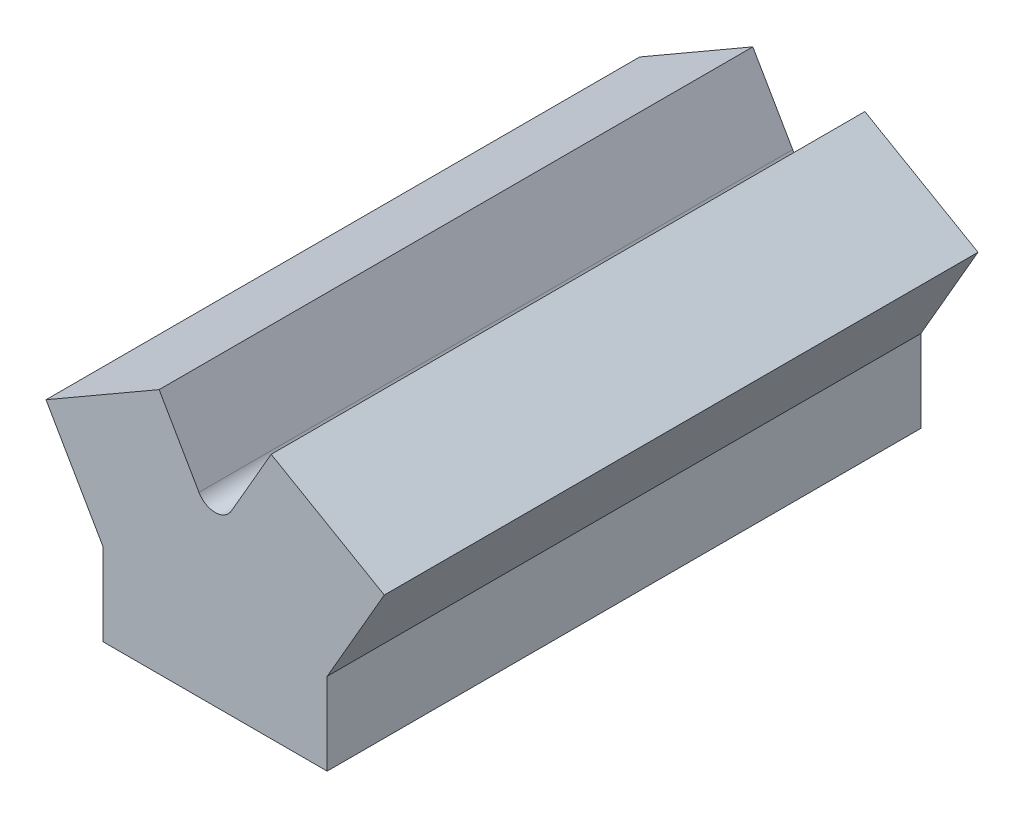
from build123d import *

# Parameters (mm, degrees)
BOSS_EXTRUDE1_DEPTH = 403.86
CUT_EXTRUDE1_START  = -19.05
SKETCH3_R           = 22.86
CUT_EXTRUDE1_DEPTH  = 403.86
CUT_EXTRUDE2_START  = -19.05
SKETCH2_R           = 22.86
CUT_EXTRUDE2_DEPTH  = 403.86
CUT_EXTRUDE3_START  = -25.4
CUT_EXTRUDE3_DEPTH  = 353.06
SKETCH7_R           = 6.35
CUT_EXTRUDE4_DEPTH  = 76.2


with BuildPart() as part:
    # Sketch1 → Boss-Extrude1 (new body)
    with BuildSketch(Plane.XY):
        with BuildLine():
            ThreePointArc((10.998522628, 120.65), (0, 114.3), (-10.998522628, 120.65))
            Line((-10.998522628, 120.65), (-38.114105889, 167.615567884))
            Line((-38.114105889, 167.615567884), (-115.061446619, 123.19))
            Line((-115.061446619, 123.19), (-76.2, 55.88))
            Line((-76.2, 55.88), (-76.2, 0))
            Line((-76.2, 0), (76.2, 0))
            Line((76.2, 0), (76.2, 55.88))
            Line((76.2, 55.88), (115.061446619, 123.19))
            Line((115.061446619, 123.19), (38.114105889, 167.615567884))
            Line((38.114105889, 167.615567884), (10.998522628, 120.65))
        make_face()
    extrude(amount=BOSS_EXTRUDE1_DEPTH)

    # Sketch3 → Cut-Extrude1 (cut)
    with BuildSketch(Plane(origin=(-82.108196401, 142.215567884, 0), x_dir=(0.866025404, 0.5, 0), z_dir=(-0.5, 0.866025404, 0)).offset(CUT_EXTRUDE1_START)):
        with Locations((6.374432116, -340.36)):
            Circle(SKETCH3_R)
        with Locations((6.374432116, -228.6)):
            Circle(SKETCH3_R)
        with Locations((6.374432116, -116.84)):
            Circle(SKETCH3_R)
    extrude(amount=-CUT_EXTRUDE1_DEPTH, mode=Mode.SUBTRACT)

    # Sketch2 → Cut-Extrude2 (cut)
    with BuildSketch(Plane(origin=(82.108196401, 142.215567884, 0), x_dir=(0.866025404, -0.5, 0), z_dir=(0.5, 0.866025404, 0)).offset(CUT_EXTRUDE2_START)):
        with Locations((-6.374432116, -284.48)):
            Circle(SKETCH2_R)
        with Locations((-6.374432116, -172.72)):
            Circle(SKETCH2_R)
        with Locations((-6.374432116, -60.96)):
            Circle(SKETCH2_R)
    extrude(amount=-CUT_EXTRUDE2_DEPTH, mode=Mode.SUBTRACT)

    # Sketch6 → Cut-Extrude3 (cut)
    with BuildSketch(Plane.XY.offset(403.86).offset(CUT_EXTRUDE3_START)):
        with BuildLine():
            Line((50.8, 0), (50.8, 31.75))
            Line((50.8, 31.75), (26.311519178, 45.814017315))
            ThreePointArc((26.311519178, 45.814017315), (0, 52.832), (-26.311519178, 45.814017315))
            Line((-26.311519178, 45.814017315), (-50.8, 31.75))
            Line((-50.8, 31.75), (-50.8, 0))
            Line((-50.8, 0), (50.8, 0))
        make_face()
    extrude(amount=-CUT_EXTRUDE3_DEPTH, mode=Mode.SUBTRACT)

    # Sketch7 → Cut-Extrude4 (cut)
    with BuildSketch(Plane.XZ):
        with Locations((63.5, 391.16)):
            Circle(SKETCH7_R)
        with Locations((-63.5, 12.7)):
            Circle(SKETCH7_R)
    extrude(amount=-CUT_EXTRUDE4_DEPTH, mode=Mode.SUBTRACT)


solid = part.part
